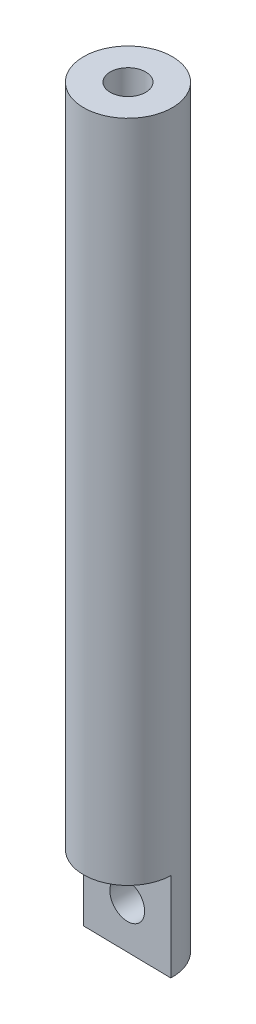
from build123d import *

# Parameters (mm, degrees)
SKETCH1_R           = 5
BOSS_EXTRUDE1_DEPTH = 85
SKETCH2_R           = 2
CUT_EXTRUDE1_DEPTH  = 15
CUT_EXTRUDE2_DEPTH  = 10
SKETCH4_R           = 2
CUT_EXTRUDE3_DEPTH  = 6.165903358


with BuildPart() as part:
    # Sketch1 → Boss-Extrude1 (new body)
    with BuildSketch(Plane(origin=(0, 0, 0), x_dir=(1, 0, 0), z_dir=(0, 1, 0))):
        Circle(SKETCH1_R)
    extrude(amount=BOSS_EXTRUDE1_DEPTH)

    # Sketch2 → Cut-Extrude1 (cut)
    with BuildSketch(Plane(origin=(0, 85, 0), x_dir=(1, 0, 0), z_dir=(0, 1, 0))):
        Circle(SKETCH2_R)
    extrude(amount=-CUT_EXTRUDE1_DEPTH, mode=Mode.SUBTRACT)

    # Sketch3 → Cut-Extrude2 (cut)
    with BuildSketch(Plane.XZ):
        with BuildLine():
            Line((-5, 0), (4.997224535, 0.166574151))
            ThreePointArc((4.997224535, 0.166574151), (-0.084674808, 5.081899343), (-5, 0))
        make_face()
    extrude(amount=-CUT_EXTRUDE2_DEPTH, mode=Mode.SUBTRACT)

    # Sketch4 → Cut-Extrude3 (cut, through all)
    with BuildSketch(Plane(origin=(-0.001387733, 0, 0.083287076), x_dir=(0.999861217, 0, 0.016659727), z_dir=(-0.016659727, 0, 0.999861217))):
        with Locations((0, 5)):
            Circle(SKETCH4_R)
    extrude(amount=-CUT_EXTRUDE3_DEPTH, mode=Mode.SUBTRACT)


solid = part.part
